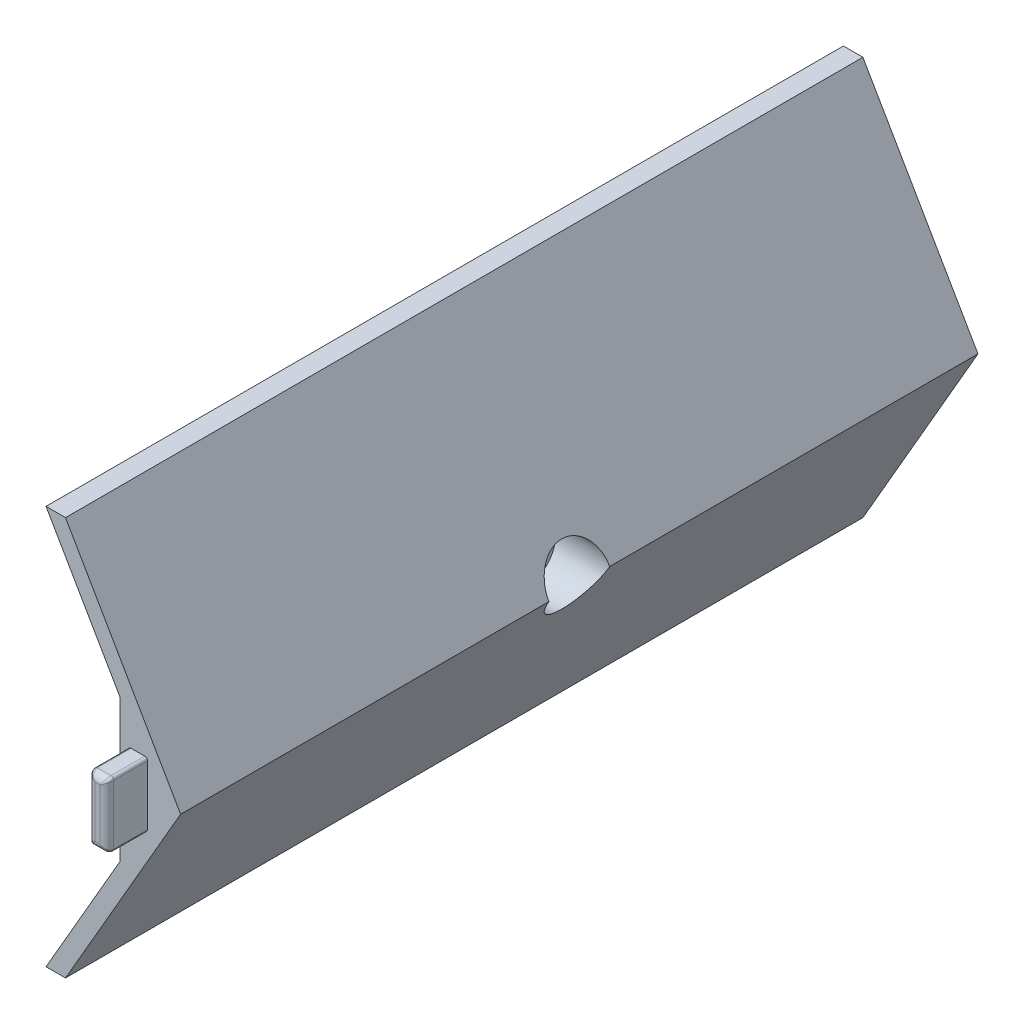
from build123d import *

# Parameters (mm, degrees)
BOSS_EXTRUDE1_DEPTH = 29.5
BOSS_EXTRUDE2_DEPTH = 59
SKETCH3_W           = 1.4
SKETCH3_H           = 4.8
BOSS_EXTRUDE3_DEPTH = 3
FILLET1_R           = 0.5
SKETCH5_R           = 1.2
CUT_EXTRUDE1_DEPTH  = 13
SKETCH6_R           = 2.25
CUT_EXTRUDE2_DEPTH  = 5
FILLET2_R           = 0.2


with BuildPart() as part:
    # Sketch1 → Boss-Extrude1 (new body, symmetric)
    with BuildSketch(Plane.XY):
        Polygon((17.556624327, 0), (9.040707856, 14.75), (10.484083529, 14.75), (19, 0), (10.484083529, -14.75), (9.040707856, -14.75), align=None)
    extrude(amount=BOSS_EXTRUDE1_DEPTH, both=True)

    # Sketch2 → Boss-Extrude2 (add)
    with BuildSketch(Plane.XY.offset(29.5)):
        Polygon((17.556624327, 0), (14.5, 5.294228634), (14.5, -5.294228634), align=None)
    extrude(amount=-BOSS_EXTRUDE2_DEPTH)

    # Sketch3 → Boss-Extrude3 (add)
    with BuildSketch(Plane.XY.offset(29.5)):
        with Locations((15.85, 0)):
            Rectangle(SKETCH3_W, SKETCH3_H)
    extrude(amount=BOSS_EXTRUDE3_DEPTH)

    # Fillet1
    fillet1_edges = [part.edges().sort_by_distance(p)[0] for p in [
        (15.15, 0, 32.5),
        (15.85, -2.4, 32.5),
        (16.55, 0, 32.5),
        (15.85, 2.4, 32.5),
    ]]
    fillet(fillet1_edges, radius=FILLET1_R)

    # Sketch5 → Cut-Extrude1 (cut)
    with BuildSketch(Plane(origin=(20, 0, 0), x_dir=(0, 0, -1), z_dir=(1, 0, 0))):
        Circle(SKETCH5_R)
    extrude(amount=-CUT_EXTRUDE1_DEPTH, mode=Mode.SUBTRACT)

    # Sketch6 → Cut-Extrude2 (cut)
    with BuildSketch(Plane(origin=(20, 0, 0), x_dir=(0, 0, -1), z_dir=(1, 0, 0))):
        Circle(SKETCH6_R)
    extrude(amount=-CUT_EXTRUDE2_DEPTH, mode=Mode.SUBTRACT)

    # Fillet2
    fillet2_edges = [part.edges().sort_by_distance(p)[0] for p in [
        (15.15, 2.4, 30.75),
        (16.55, 2.4, 30.75),
        (16.55, -2.4, 30.75),
        (15.15, -2.4, 30.75),
        (16.373024454, -2.223024454, 32.381648008),
        (15.326975546, -2.223024454, 32.381648008),
        (16.373024454, 2.223024454, 32.381648008),
        (15.326975546, 2.223024454, 32.381648008),
    ]]
    fillet(fillet2_edges, radius=FILLET2_R)


solid = part.part
